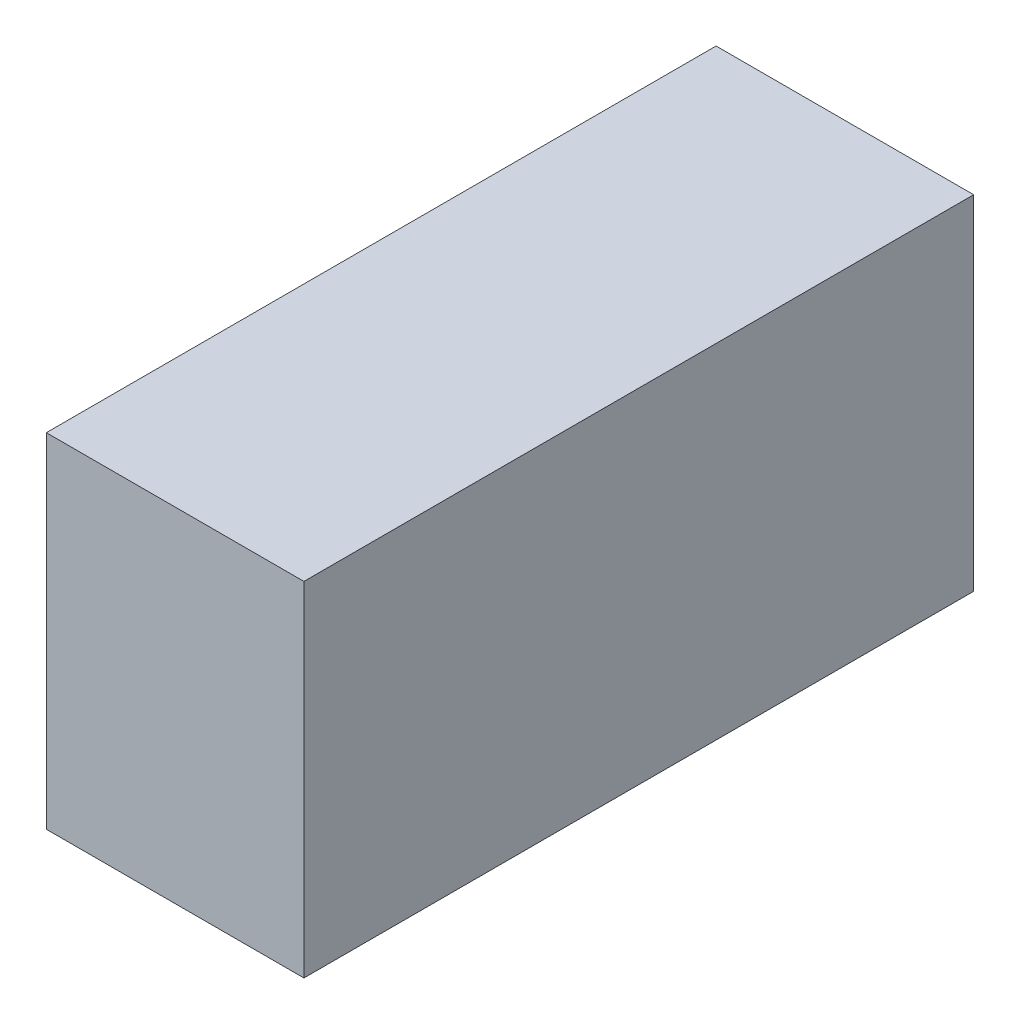
from build123d import *

# Parameters (mm, degrees)
SKETCH3_W                = 9.525
SKETCH3_H                = 12.7
BOSS_EXTRUDE1_DEPTH      = 12.3825
BOSS_EXTRUDE1_DEPTH_BACK = 12.3825


with BuildPart() as part:
    # Sketch3 → Boss-Extrude1 (new body, two sides)
    with BuildSketch(Plane.XY) as boss_extrude1_sk:
        Rectangle(SKETCH3_W, SKETCH3_H)
    extrude(amount=BOSS_EXTRUDE1_DEPTH)
    extrude(boss_extrude1_sk.sketch, amount=-BOSS_EXTRUDE1_DEPTH_BACK)


solid = part.part
